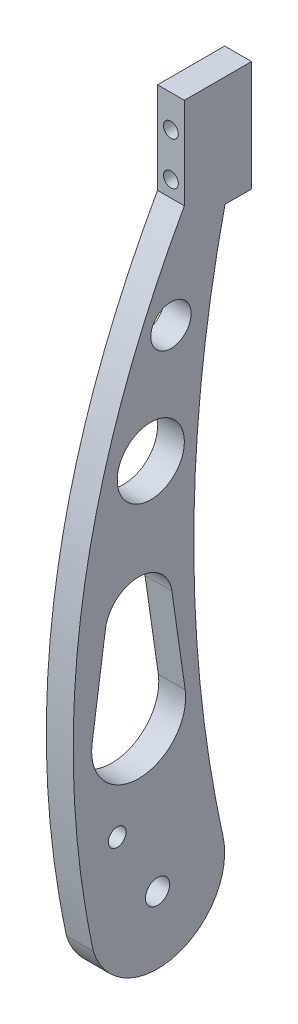
from build123d import *

# Parameters (mm, degrees)
SKETCH1_R                = 7.5
SKETCH1_R_2              = 12.5
BOSS_EXTRUDE1_DEPTH      = 10
M5_CLEARANCE_HOLE2_D     = 5.5
M5_CLEARANCE_HOLE2_DEPTH = 30
M5_CLEARANCE_HOLE2_TIP   = 1.652366702
M8_CLEARANCE_HOLE1_D     = 9
M8_CLEARANCE_HOLE1_DEPTH = 30
M8_CLEARANCE_HOLE1_TIP   = 2.703872786
M6_CLEARANCE_HOLE1_D     = 6.6
M6_CLEARANCE_HOLE1_DEPTH = 30
M6_CLEARANCE_HOLE1_TIP   = 1.982840043


with BuildPart() as part:
    # Sketch1 → Boss-Extrude1 (new body)
    with BuildSketch(Plane(origin=(0, 0, 0), x_dir=(0, 0, -1), z_dir=(1, 0, 0))):
        with BuildLine():
            Line((10, 215.979685497), (10, 250))
            Line((10, 250), (25, 250))
            Line((25, 250), (35, 250))
            Line((35, 250), (35, 208.897946033))
            Line((35, 208.897946033), (25.122964317, 208.897946033))
            ThreePointArc((25.122964317, 208.897946033), (13.508598299, 107.244900729), (24.385178415, 5.510269837))
            ThreePointArc((24.385178415, 5.510269837), (6.422608809, -24.160920845), (-23.902542108, -7.325877476))
            add(Edge.make_bspline(
                [(-23.902542108, -7.325877476), (-48.990185726, 110.151133061), (10, 215.979685497)],
                knots=[0, 0, 0, 1, 1, 1], degree=2))
        make_face()
        with Locations((5, 180)):
            Circle(SKETCH1_R, mode=Mode.SUBTRACT)
        with Locations((-2.5, 140)):
            Circle(SKETCH1_R_2, mode=Mode.SUBTRACT)
        with BuildLine():
            Line((-24.338949666, 59.866716225), (-19.390233073, 94.152430511))
            ThreePointArc((-19.390233073, 94.152430511), (-7.01844159, 104.866716225), (5.353349892, 94.152430511))
            Line((5.353349892, 94.152430511), (10.302066485, 59.866716225))
            ThreePointArc((10.302066485, 59.866716225), (-7.01844159, 39.866716225), (-24.338949666, 59.866716225))
        make_face(mode=Mode.SUBTRACT)
    extrude(amount=BOSS_EXTRUDE1_DEPTH)

    # M5 Clearance Hole2
    with Locations(Plane(origin=(0, 0, -35), x_dir=(-1, 0, 0), z_dir=(0, 0, -1))):
        with Locations((-4.98385201, 238), (-4.98385201, 222)):
            Hole(M5_CLEARANCE_HOLE2_D / 2, depth=M5_CLEARANCE_HOLE2_DEPTH)
            with Locations((0, 0, -(M5_CLEARANCE_HOLE2_DEPTH + M5_CLEARANCE_HOLE2_TIP / 2))):  # 118° drill point
                Cone(0, M5_CLEARANCE_HOLE2_D / 2, M5_CLEARANCE_HOLE2_TIP, mode=Mode.SUBTRACT)

    # M8 Clearance Hole1
    with Locations(Plane(origin=(10, 0, 0), x_dir=(0, 0, -1), z_dir=(1, 0, 0))):
        with Locations((0, 0)):
            Hole(M8_CLEARANCE_HOLE1_D / 2, depth=M8_CLEARANCE_HOLE1_DEPTH)
            with Locations((0, 0, -(M8_CLEARANCE_HOLE1_DEPTH + M8_CLEARANCE_HOLE1_TIP / 2))):  # 118° drill point
                Cone(0, M8_CLEARANCE_HOLE1_D / 2, M8_CLEARANCE_HOLE1_TIP, mode=Mode.SUBTRACT)

    # M6 Clearance Hole1
    with Locations(Plane.ZY):
        with Locations((15, 25)):
            Hole(M6_CLEARANCE_HOLE1_D / 2, depth=M6_CLEARANCE_HOLE1_DEPTH)
            with Locations((0, 0, -(M6_CLEARANCE_HOLE1_DEPTH + M6_CLEARANCE_HOLE1_TIP / 2))):  # 118° drill point
                Cone(0, M6_CLEARANCE_HOLE1_D / 2, M6_CLEARANCE_HOLE1_TIP, mode=Mode.SUBTRACT)


solid = part.part
